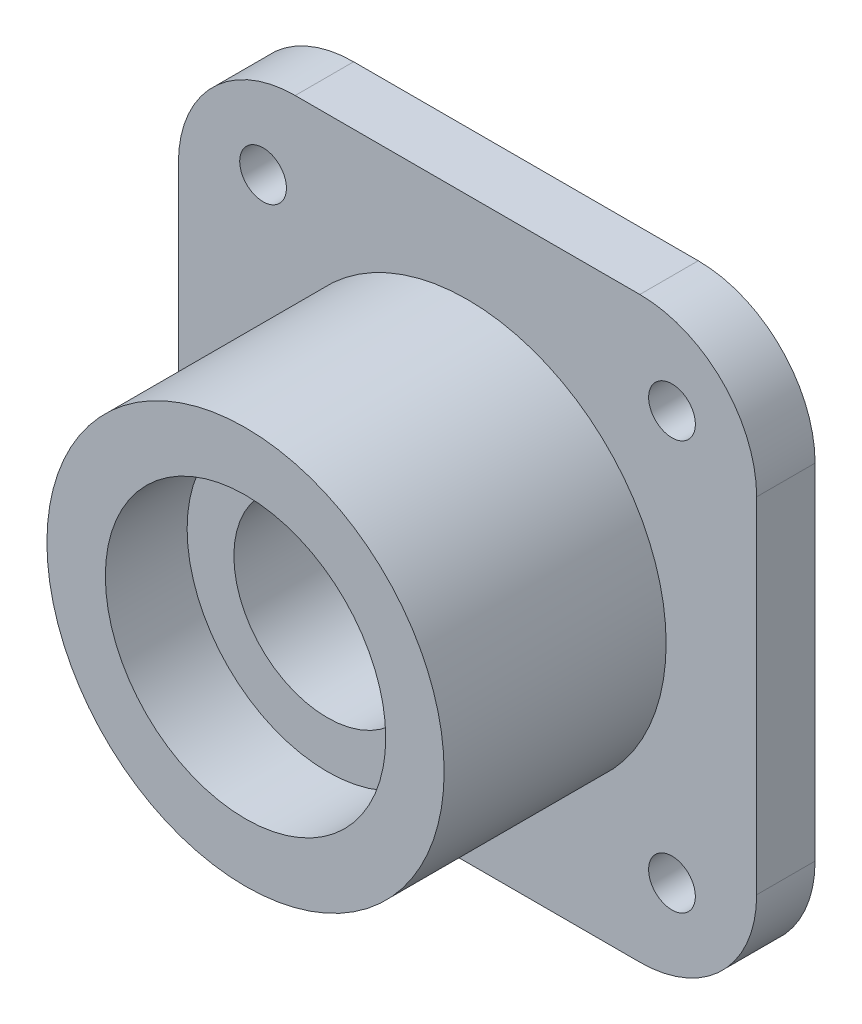
from build123d import *

# Parameters (mm, degrees)
CUT_EXTRUDE1_DEPTH = 10
FILLET1_R          = 10
SKETCH5_R          = 2
CUT_EXTRUDE2_DEPTH = 10


with BuildPart() as part:
    # Sketch3 → Revolve1 (revolve)
    with BuildSketch(Plane(origin=(0, 0, 0), x_dir=(0, 0, -1), z_dir=(1, 0, 0))):
        Polygon((0, 12), (7, 12), (7, 8), (17, 8), (17, 12), (24, 12), (24, 35), (19, 35), (19, 17), (0, 17), align=None)
    revolve(axis=Axis((0, 0, 0), (0, 0, -1)))

    # Sketch4 → Cut-Extrude1 (cut)
    with BuildSketch(Plane.XY.offset(-19)):
        with BuildLine():
            ThreePointArc((35, 0), (32.335783638, 13.393920133), (24.748737342, 24.748737342))
            Line((24.748737342, 24.748737342), (24.748737342, -24.748737342))
            ThreePointArc((24.748737342, -24.748737342), (32.335783638, -13.393920133), (35, 0))
        make_face()
        with BuildLine():
            ThreePointArc((24.748737342, 24.748737342), (0, 35), (-24.748737342, 24.748737342))
            Line((-24.748737342, 24.748737342), (24.748737342, 24.748737342))
        make_face()
        with BuildLine():
            Line((-24.748737342, -24.748737342), (-24.748737342, 24.748737342))
            ThreePointArc((-24.748737342, 24.748737342), (-35, 0), (-24.748737342, -24.748737342))
        make_face()
        with BuildLine():
            Line((24.748737342, -24.748737342), (-24.748737342, -24.748737342))
            ThreePointArc((-24.748737342, -24.748737342), (0, -35), (24.748737342, -24.748737342))
        make_face()
    extrude(amount=-CUT_EXTRUDE1_DEPTH, mode=Mode.SUBTRACT)

    # Fillet1
    fillet1_edges = [part.edges().sort_by_distance(p)[0] for p in [
        (24.748737342, 24.748737342, -21.5),
        (24.748737342, -24.748737342, -21.5),
        (-24.748737342, 24.748737342, -21.5),
        (-24.748737342, -24.748737342, -21.5),
    ]]
    fillet(fillet1_edges, radius=FILLET1_R)

    # Sketch5 → Cut-Extrude2 (cut)
    with BuildSketch(Plane(origin=(0, 0, -24), x_dir=(-1, 0, 0), z_dir=(0, 0, -1))):
        with Locations((-17.5, 17.5)):
            Circle(SKETCH5_R)
        with Locations((17.5, 17.5)):
            Circle(SKETCH5_R)
        with Locations((17.5, -17.5)):
            Circle(SKETCH5_R)
        with Locations((-17.5, -17.5)):
            Circle(SKETCH5_R)
    extrude(amount=-CUT_EXTRUDE2_DEPTH, mode=Mode.SUBTRACT)


solid = part.part
